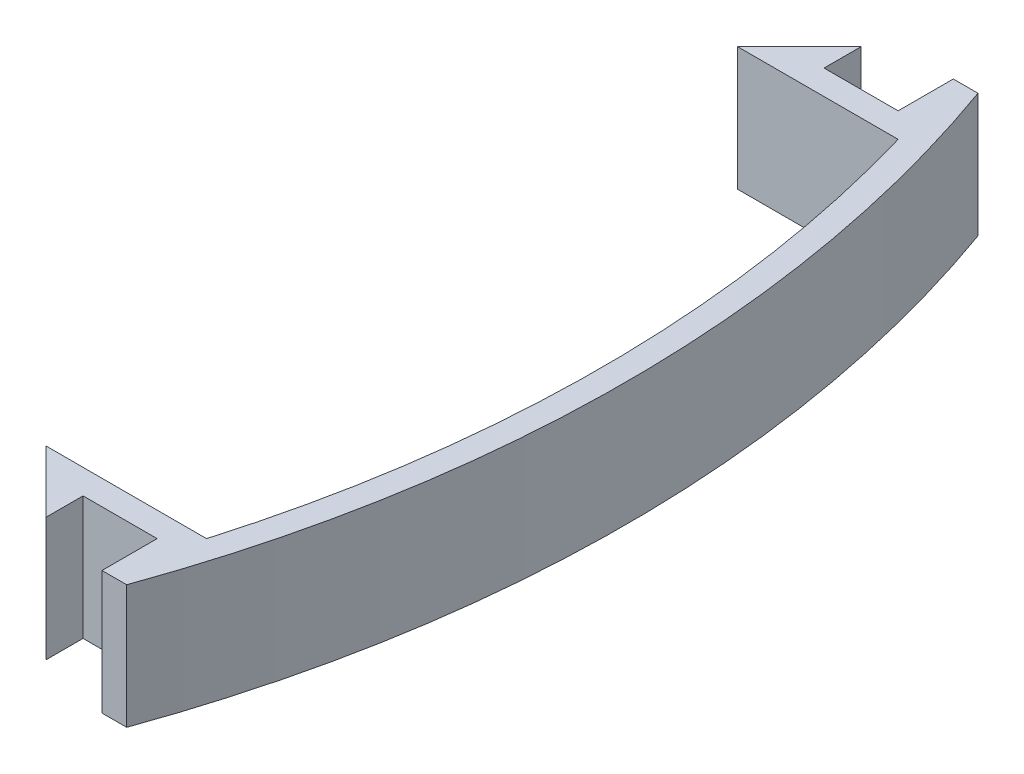
from build123d import *

# Parameters (mm, degrees)
BOSS_EXTRU_1_DEPTH = 10


with BuildPart() as part:
    # Esquisse1 → Boss.-Extru.1 (new body)
    with BuildSketch(Plane(origin=(0, 0, 0), x_dir=(1, 0, 0), z_dir=(0, 1, 0))):
        with BuildLine():
            Line((0, -28), (-13, -28))
            Line((-13, -28), (-8, -33))
            Line((-8, -33), (-8, -30))
            Line((-8, -30), (-2, -30))
            Line((-2, -30), (-2, -34.467375879))
            Line((-2, -34.467375879), (0, -34.467375879))
            ThreePointArc((0, -34.467375879), (6, 0), (0, 34.467375879))
            Line((0, 34.467375879), (-2, 34.467375879))
            Line((-2, 34.467375879), (-2, 30))
            Line((-2, 30), (-8, 30))
            Line((-8, 30), (-8, 33))
            Line((-8, 33), (-13, 28))
            Line((-13, 28), (0, 28))
            ThreePointArc((0, 28), (4, 0), (0, -28))
        make_face()
    extrude(amount=BOSS_EXTRU_1_DEPTH)


solid = part.part
